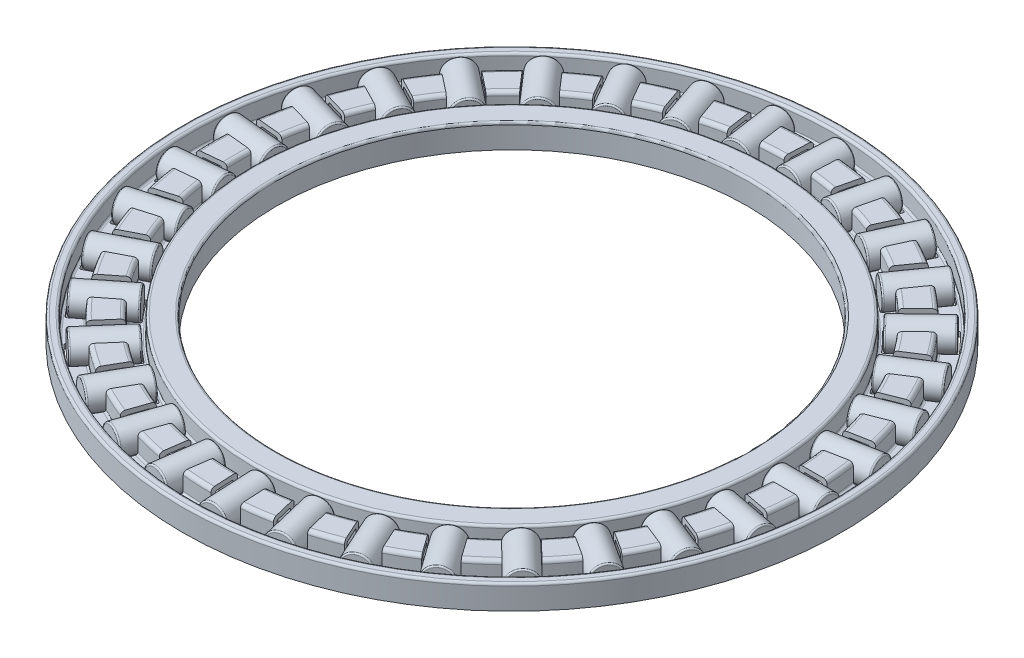
from build123d import *

# Parameters (mm, degrees)
FILLET1_R                = 0.4
FILLET2_R                = 0.4
FILLET3_R                = 0.25
FILLET4_R                = 0.2
CUT_EXTRUDE1_DEPTH       = 2.275
FILLET5_R                = 0.150049647
CIRPATTERN1_COUNT        = 33
FILLET5_OF_CIRPATTERN1_R = 0.150049647
SKETCH5_W                = 5.555300686
SKETCH5_H                = 1.5
FILLET6_R                = 0.150049647
CIRPATTERN2_COUNT        = 33


with BuildPart() as part:
    # Sketch3 → Revolve1 (revolve)
    with BuildSketch(Plane(origin=(0, 0, 0), x_dir=(0, 0, -1), z_dir=(1, 0, 0))):
        Polygon((25.85, -1.275), (25.85, 0.779166667), (26.675, 0.779166667), (26.675, -1.275), (29.504166667, -1.275), (29.504166667, 0.779166667), (31.504166667, 0.779166667), (31.504166667, -1.275), (34.333333333, -1.275), (34.333333333, 0.779166667), (34.666666667, 0.779166667), (34.666666667, -1.275), (35, -1.275), (35, 1.275), (34, 1.275), (34, -0.779166667), (32, -0.779166667), (32, 1.275), (29.008333333, 1.275), (29.008333333, -0.779166667), (27.5, -0.779166667), (27.5, 1.275), (25.025, 1.275), (25.025, -1.275), align=None)
    revolve(axis=Axis((0, 1.5, 0), (0, -1, 0)))

    # Fillet1
    fillet1_edges = [part.edges().sort_by_distance(p)[0] for p in [
        (0, -1.275, 34.333333333),
        (0, -1.275, 31.504166667),
        (0, -1.275, 29.504166667),
        (0, -1.275, 26.675),
    ]]
    fillet(fillet1_edges, radius=FILLET1_R)

    # Fillet2
    fillet2_edges = [part.edges().sort_by_distance(p)[0] for p in [
        (0, 1.275, 29.008333333),
        (0, 1.275, 32),
    ]]
    fillet(fillet2_edges, radius=FILLET2_R)

    # Fillet3
    fillet3_edges = [part.edges().sort_by_distance(p)[0] for p in [
        (0, 1.275, 25.025),
        (0, 1.275, 27.5),
        (0, 1.275, 34),
        (0, 1.275, 35),
    ]]
    fillet(fillet3_edges, radius=FILLET3_R)

    # Fillet4
    fillet4_edges = [part.edges().sort_by_distance(p)[0] for p in [
        (0, -0.779166667, 27.5),
        (0, -0.779166667, 29.008333333),
        (0, -0.779166667, 32),
        (0, -0.779166667, 34),
        (0, 0.779166667, 31.504166667),
        (0, 0.779166667, 29.504166667),
    ]]
    fillet(fillet4_edges, radius=FILLET4_R)

    # Sketch4 → Cut-Extrude1 (cut, symmetric)
    with BuildSketch(Plane(origin=(0, 0, 0), x_dir=(1, 0, 0), z_dir=(0, 1, 0))):
        with BuildLine():
            Line((27.784539316, 1.5), (33.64157584, 1.5))
            ThreePointArc((33.64157584, 1.5), (33.675, 0), (33.64157584, -1.5))
            Line((33.64157584, -1.5), (27.784539316, -1.5))
            ThreePointArc((27.784539316, -1.5), (27.825, 0), (27.784539316, 1.5))
        make_face()
    cut_extrude1 = extrude(amount=CUT_EXTRUDE1_DEPTH, both=True, mode=Mode.SUBTRACT)

    # Fillet5
    fillet5_edges = [part.edges().sort_by_distance(p)[0] for p in [
        (33.64157584, -1.027083333, -1.5),
        (27.784539316, -1.027083333, 1.5),
        (27.784539316, -1.027083333, -1.5),
        (33.64157584, -1.027083333, 1.5),
    ]]
    fillet(fillet5_edges, radius=FILLET5_R)

    # CirPattern1: Cut-Extrude1 ×33 about axis
    cirpattern1_axis = Axis((0, 0, 0), (0, 1, 0))
    for i in range(1, CIRPATTERN1_COUNT):
        add(cut_extrude1.rotate(cirpattern1_axis, i * 360 / CIRPATTERN1_COUNT), mode=Mode.SUBTRACT)

    # Fillet5 of CirPattern1
    fillet5_of_cirpattern1_edges = [part.edges().sort_by_distance(p)[0] for p in [
        (32.749751872, -1.027083333, -7.839603136),
        (27.566313361, -1.027083333, -3.785365594),
        (26.998559628, -1.027083333, -6.731151685),
        (33.317505605, -1.027083333, -4.893817044),
        (30.674266543, -1.027083333, -13.895862589),
        (26.351769018, -1.027083333, -8.933918212),
        (25.236781651, -1.027083333, -11.719022011),
        (31.789253909, -1.027083333, -11.110758789),
        (27.490133299, -1.027083333, -19.449889362),
        (24.184803084, -1.027083333, -13.759575749),
        (22.562880631, -1.027083333, -16.283336348),
        (29.112055752, -1.027083333, -16.926128763),
        (23.312435014, -1.027083333, -24.300946458),
        (21.143735353, -1.027083333, -18.087926368),
        (19.073498319, -1.027083333, -20.259128483),
        (25.382672048, -1.027083333, -22.129744343),
        (18.292164587, -1.027083333, -28.273704033),
        (17.338477938, -1.027083333, -21.762532201),
        (14.894750081, -1.027083333, -23.50270293),
        (20.735892443, -1.027083333, -26.533533304),
        (12.610767672, -1.027083333, -31.224576278),
        (12.906562754, -1.027083333, -24.650583418),
        (10.177666768, -1.027083333, -25.896828457),
        (15.339663658, -1.027083333, -29.978331239),
        (6.473584756, -1.027083333, -33.046910981),
        (8.008170765, -1.027083333, -26.647698325),
        (5.09273606, -1.027083333, -27.354975131),
        (9.389019461, -1.027083333, -32.339634175),
        (0.102429621, -1.027083333, -33.674844219),
        (2.82034262, -1.027083333, -27.681695983),
        (-0.176259398, -1.027083333, -27.824441731),
        (3.099031639, -1.027083333, -33.532098472),
        (-6.272427588, -1.027083333, -33.085680848),
        (-2.469420056, -1.027083333, -27.715205025),
        (-5.438884382, -1.027083333, -27.28826051),
        (-3.302963262, -1.027083333, -33.512625363),
        (-12.420582921, -1.027083333, -31.300714767),
        (-7.669931458, -1.027083333, -26.747014346),
        (-10.504933914, -1.027083333, -25.765810456),
        (-9.585580465, -1.027083333, -32.281918657),
        (-18.119826026, -1.027083333, -28.384459301),
        (-12.593231552, -1.027083333, -24.81211688),
        (-15.191307764, -1.027083333, -23.31211688),
        (-15.521749814, -1.027083333, -29.884459301),
        (-23.164171407, -1.027083333, -24.442315521),
        (-17.061379447, -1.027083333, -21.980444863),
        (-19.32862817, -1.027083333, -20.015862661),
        (-20.896922684, -1.027083333, -26.406897723),
        (-27.37130328, -1.027083333, -19.616762774),
        (-20.912884636, -1.027083333, -18.354342298),
        (-22.767361595, -1.027083333, -15.996183014),
        (-25.516826322, -1.027083333, -21.974922058),
        (-30.589164938, -1.027083333, -14.08220911),
        (-24.008543686, -1.027083333, -14.064865982),
        (-25.383223251, -1.027083333, -11.398359636),
        (-29.214485373, -1.027083333, -16.748715456),
        (-32.701454475, -1.027083333, -8.038687717),
        (-26.236471414, -1.027083333, -9.267048763),
        (-27.081669084, -1.027083333, -6.388569842),
        (-31.856256805, -1.027083333, -10.917166638),
        (-33.631828245, -1.027083333, -1.704627206),
        (-27.516144706, -1.027083333, -4.134296256),
        (-27.801312836, -1.027083333, -1.147880489),
        (-33.346660115, -1.027083333, -4.691042974),
        (-33.346660115, -1.027083333, 4.691042974),
        (-27.801312836, -1.027083333, 1.147880489),
        (-27.516144706, -1.027083333, 4.134296256),
        (-33.631828245, -1.027083333, 1.704627206),
        (-31.856256805, -1.027083333, 10.917166638),
        (-27.081669084, -1.027083333, 6.388569842),
        (-26.236471414, -1.027083333, 9.267048763),
        (-32.701454475, -1.027083333, 8.038687717),
        (-29.214485373, -1.027083333, 16.748715456),
        (-25.383223251, -1.027083333, 11.398359636),
        (-24.008543686, -1.027083333, 14.064865982),
        (-30.589164938, -1.027083333, 14.08220911),
        (-25.516826322, -1.027083333, 21.974922058),
        (-22.767361595, -1.027083333, 15.996183014),
        (-20.912884636, -1.027083333, 18.354342298),
        (-27.37130328, -1.027083333, 19.616762774),
        (-20.896922684, -1.027083333, 26.406897723),
        (-19.32862817, -1.027083333, 20.015862661),
        (-17.061379447, -1.027083333, 21.980444863),
        (-23.164171407, -1.027083333, 24.442315521),
        (-15.521749814, -1.027083333, 29.884459301),
        (-15.191307764, -1.027083333, 23.31211688),
        (-12.593231552, -1.027083333, 24.81211688),
        (-18.119826026, -1.027083333, 28.384459301),
        (-9.585580465, -1.027083333, 32.281918657),
        (-10.504933914, -1.027083333, 25.765810456),
        (-7.669931458, -1.027083333, 26.747014346),
        (-12.420582921, -1.027083333, 31.300714767),
        (-3.302963262, -1.027083333, 33.512625363),
        (-5.438884382, -1.027083333, 27.28826051),
        (-2.469420056, -1.027083333, 27.715205025),
        (-6.272427588, -1.027083333, 33.085680848),
        (3.099031639, -1.027083333, 33.532098472),
        (-0.176259398, -1.027083333, 27.824441731),
        (2.82034262, -1.027083333, 27.681695983),
        (0.102429621, -1.027083333, 33.674844219),
        (9.389019461, -1.027083333, 32.339634175),
        (5.09273606, -1.027083333, 27.354975131),
        (8.008170765, -1.027083333, 26.647698325),
        (6.473584756, -1.027083333, 33.046910981),
        (15.339663658, -1.027083333, 29.978331239),
        (10.177666768, -1.027083333, 25.896828457),
        (12.906562754, -1.027083333, 24.650583418),
        (12.610767672, -1.027083333, 31.224576278),
        (20.735892443, -1.027083333, 26.533533304),
        (14.894750081, -1.027083333, 23.50270293),
        (17.338477938, -1.027083333, 21.762532201),
        (18.292164587, -1.027083333, 28.273704033),
        (25.382672048, -1.027083333, 22.129744343),
        (19.073498319, -1.027083333, 20.259128483),
        (21.143735353, -1.027083333, 18.087926368),
        (23.312435014, -1.027083333, 24.300946458),
        (29.112055752, -1.027083333, 16.926128763),
        (22.562880631, -1.027083333, 16.283336348),
        (24.184803084, -1.027083333, 13.759575749),
        (27.490133299, -1.027083333, 19.449889362),
        (31.789253909, -1.027083333, 11.110758789),
        (25.236781651, -1.027083333, 11.719022011),
        (26.351769018, -1.027083333, 8.933918212),
        (30.674266543, -1.027083333, 13.895862589),
        (33.317505605, -1.027083333, 4.893817044),
        (26.998559628, -1.027083333, 6.731151685),
        (27.566313361, -1.027083333, 3.785365594),
        (32.749751872, -1.027083333, 7.839603136),
    ]]
    fillet(fillet5_of_cirpattern1_edges, radius=FILLET5_OF_CIRPATTERN1_R)


with BuildPart() as body_2:
    # Sketch5 → Revolve2 (revolve)
    with BuildSketch(Plane(origin=(0, 0, 0), x_dir=(1, 0, 0), z_dir=(0, 1, 0))):
        with Locations((30.720109734, 0.75)):
            Rectangle(SKETCH5_W, SKETCH5_H)
    revolve(axis=Axis((33.675, 0, 0), (-1, 0, 0)))

    # Fillet6
    fillet6_edges = [body_2.edges().sort_by_distance(p)[0] for p in [
        (33.497760077, 0, 1.5),
        (27.942459391, 0, 1.5),
    ]]
    fillet(fillet6_edges, radius=FILLET6_R)


with BuildPart() as cirpattern2_1:
    # CirPattern2: pattern copy
    add(body_2.part.rotate(Axis((0, 0, 0), (0, 1, 0)), 1 * 360 / CIRPATTERN2_COUNT))


with BuildPart() as cirpattern2_2:
    # CirPattern2: pattern copy
    add(body_2.part.rotate(Axis((0, 0, 0), (0, 1, 0)), 2 * 360 / CIRPATTERN2_COUNT))


with BuildPart() as cirpattern2_3:
    # CirPattern2: pattern copy
    add(body_2.part.rotate(Axis((0, 0, 0), (0, 1, 0)), 3 * 360 / CIRPATTERN2_COUNT))


with BuildPart() as cirpattern2_4:
    # CirPattern2: pattern copy
    add(body_2.part.rotate(Axis((0, 0, 0), (0, 1, 0)), 4 * 360 / CIRPATTERN2_COUNT))


with BuildPart() as cirpattern2_5:
    # CirPattern2: pattern copy
    add(body_2.part.rotate(Axis((0, 0, 0), (0, 1, 0)), 5 * 360 / CIRPATTERN2_COUNT))


with BuildPart() as cirpattern2_6:
    # CirPattern2: pattern copy
    add(body_2.part.rotate(Axis((0, 0, 0), (0, 1, 0)), 6 * 360 / CIRPATTERN2_COUNT))


with BuildPart() as cirpattern2_7:
    # CirPattern2: pattern copy
    add(body_2.part.rotate(Axis((0, 0, 0), (0, 1, 0)), 7 * 360 / CIRPATTERN2_COUNT))


with BuildPart() as cirpattern2_8:
    # CirPattern2: pattern copy
    add(body_2.part.rotate(Axis((0, 0, 0), (0, 1, 0)), 8 * 360 / CIRPATTERN2_COUNT))


with BuildPart() as cirpattern2_9:
    # CirPattern2: pattern copy
    add(body_2.part.rotate(Axis((0, 0, 0), (0, 1, 0)), 9 * 360 / CIRPATTERN2_COUNT))


with BuildPart() as cirpattern2_10:
    # CirPattern2: pattern copy
    add(body_2.part.rotate(Axis((0, 0, 0), (0, 1, 0)), 10 * 360 / CIRPATTERN2_COUNT))


with BuildPart() as cirpattern2_11:
    # CirPattern2: pattern copy
    add(body_2.part.rotate(Axis((0, 0, 0), (0, 1, 0)), 11 * 360 / CIRPATTERN2_COUNT))


with BuildPart() as cirpattern2_12:
    # CirPattern2: pattern copy
    add(body_2.part.rotate(Axis((0, 0, 0), (0, 1, 0)), 12 * 360 / CIRPATTERN2_COUNT))


with BuildPart() as cirpattern2_13:
    # CirPattern2: pattern copy
    add(body_2.part.rotate(Axis((0, 0, 0), (0, 1, 0)), 13 * 360 / CIRPATTERN2_COUNT))


with BuildPart() as cirpattern2_14:
    # CirPattern2: pattern copy
    add(body_2.part.rotate(Axis((0, 0, 0), (0, 1, 0)), 14 * 360 / CIRPATTERN2_COUNT))


with BuildPart() as cirpattern2_15:
    # CirPattern2: pattern copy
    add(body_2.part.rotate(Axis((0, 0, 0), (0, 1, 0)), 15 * 360 / CIRPATTERN2_COUNT))


with BuildPart() as cirpattern2_16:
    # CirPattern2: pattern copy
    add(body_2.part.rotate(Axis((0, 0, 0), (0, 1, 0)), 16 * 360 / CIRPATTERN2_COUNT))


with BuildPart() as cirpattern2_17:
    # CirPattern2: pattern copy
    add(body_2.part.rotate(Axis((0, 0, 0), (0, 1, 0)), 17 * 360 / CIRPATTERN2_COUNT))


with BuildPart() as cirpattern2_18:
    # CirPattern2: pattern copy
    add(body_2.part.rotate(Axis((0, 0, 0), (0, 1, 0)), 18 * 360 / CIRPATTERN2_COUNT))


with BuildPart() as cirpattern2_19:
    # CirPattern2: pattern copy
    add(body_2.part.rotate(Axis((0, 0, 0), (0, 1, 0)), 19 * 360 / CIRPATTERN2_COUNT))


with BuildPart() as cirpattern2_20:
    # CirPattern2: pattern copy
    add(body_2.part.rotate(Axis((0, 0, 0), (0, 1, 0)), 20 * 360 / CIRPATTERN2_COUNT))


with BuildPart() as cirpattern2_21:
    # CirPattern2: pattern copy
    add(body_2.part.rotate(Axis((0, 0, 0), (0, 1, 0)), 21 * 360 / CIRPATTERN2_COUNT))


with BuildPart() as cirpattern2_22:
    # CirPattern2: pattern copy
    add(body_2.part.rotate(Axis((0, 0, 0), (0, 1, 0)), 22 * 360 / CIRPATTERN2_COUNT))


with BuildPart() as cirpattern2_23:
    # CirPattern2: pattern copy
    add(body_2.part.rotate(Axis((0, 0, 0), (0, 1, 0)), 23 * 360 / CIRPATTERN2_COUNT))


with BuildPart() as cirpattern2_24:
    # CirPattern2: pattern copy
    add(body_2.part.rotate(Axis((0, 0, 0), (0, 1, 0)), 24 * 360 / CIRPATTERN2_COUNT))


with BuildPart() as cirpattern2_25:
    # CirPattern2: pattern copy
    add(body_2.part.rotate(Axis((0, 0, 0), (0, 1, 0)), 25 * 360 / CIRPATTERN2_COUNT))


with BuildPart() as cirpattern2_26:
    # CirPattern2: pattern copy
    add(body_2.part.rotate(Axis((0, 0, 0), (0, 1, 0)), 26 * 360 / CIRPATTERN2_COUNT))


with BuildPart() as cirpattern2_27:
    # CirPattern2: pattern copy
    add(body_2.part.rotate(Axis((0, 0, 0), (0, 1, 0)), 27 * 360 / CIRPATTERN2_COUNT))


with BuildPart() as cirpattern2_28:
    # CirPattern2: pattern copy
    add(body_2.part.rotate(Axis((0, 0, 0), (0, 1, 0)), 28 * 360 / CIRPATTERN2_COUNT))


with BuildPart() as cirpattern2_29:
    # CirPattern2: pattern copy
    add(body_2.part.rotate(Axis((0, 0, 0), (0, 1, 0)), 29 * 360 / CIRPATTERN2_COUNT))


with BuildPart() as cirpattern2_30:
    # CirPattern2: pattern copy
    add(body_2.part.rotate(Axis((0, 0, 0), (0, 1, 0)), 30 * 360 / CIRPATTERN2_COUNT))


with BuildPart() as cirpattern2_31:
    # CirPattern2: pattern copy
    add(body_2.part.rotate(Axis((0, 0, 0), (0, 1, 0)), 31 * 360 / CIRPATTERN2_COUNT))


with BuildPart() as cirpattern2_32:
    # CirPattern2: pattern copy
    add(body_2.part.rotate(Axis((0, 0, 0), (0, 1, 0)), 32 * 360 / CIRPATTERN2_COUNT))


solid = Compound([part.part, body_2.part, cirpattern2_1.part, cirpattern2_2.part, cirpattern2_3.part, cirpattern2_4.part, cirpattern2_5.part, cirpattern2_6.part, cirpattern2_7.part, cirpattern2_8.part, cirpattern2_9.part, cirpattern2_10.part, cirpattern2_11.part, cirpattern2_12.part, cirpattern2_13.part, cirpattern2_14.part, cirpattern2_15.part, cirpattern2_16.part, cirpattern2_17.part, cirpattern2_18.part, cirpattern2_19.part, cirpattern2_20.part, cirpattern2_21.part, cirpattern2_22.part, cirpattern2_23.part, cirpattern2_24.part, cirpattern2_25.part, cirpattern2_26.part, cirpattern2_27.part, cirpattern2_28.part, cirpattern2_29.part, cirpattern2_30.part, cirpattern2_31.part, cirpattern2_32.part])
